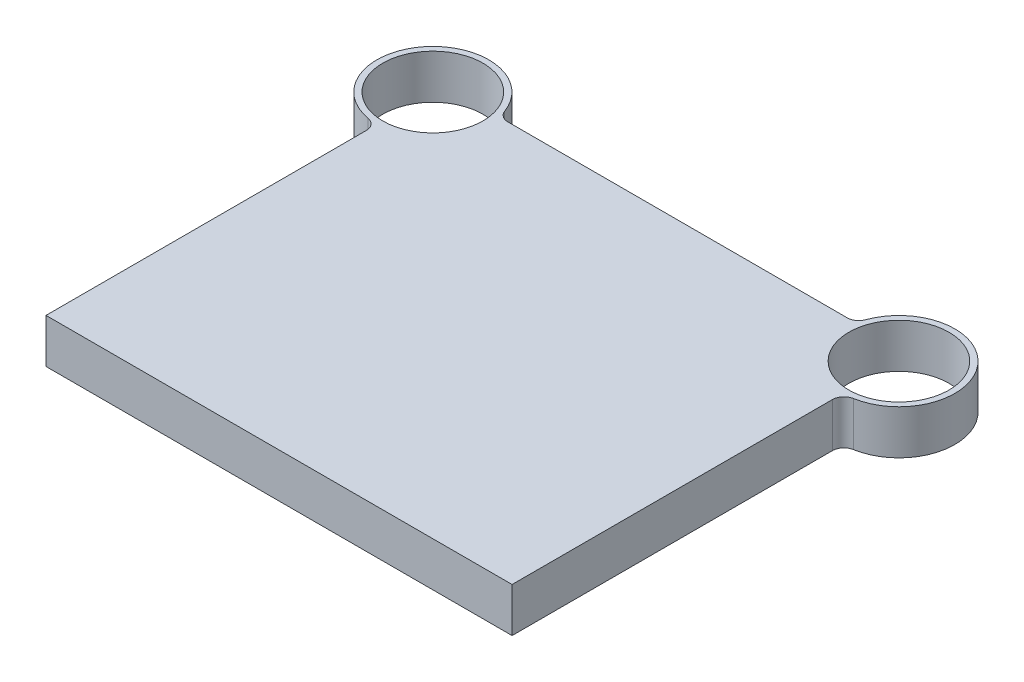
from build123d import *

# Parameters (mm, degrees)
SKETCH1_R           = 43
BOSS_EXTRUDE1_DEPTH = 38
FILLET1_R           = 10


with BuildPart() as part:
    # Sketch1 → Boss-Extrude1 (new body)
    with BuildSketch(Plane(origin=(0, 0, 0), x_dir=(1, 0, 0), z_dir=(0, 1, 0))):
        with BuildLine():
            Line((200, 0), (-200, 0))
            Line((-200, 0), (-200, 284))
            ThreePointArc((-200, 284), (-237.309516212, 362.199337741), (-153.053221623, 342))
            Line((-153.053221623, 342), (153.053221623, 342))
            ThreePointArc((153.053221623, 342), (237.309516212, 362.199337741), (200, 284))
            Line((200, 284), (200, 0))
        make_face()
        with Locations((-200, 332)):
            Circle(SKETCH1_R, mode=Mode.SUBTRACT)
        with Locations((200, 332)):
            Circle(SKETCH1_R, mode=Mode.SUBTRACT)
    extrude(amount=BOSS_EXTRUDE1_DEPTH)

    # Fillet1
    fillet1_edges = [part.edges().sort_by_distance(p)[0] for p in [
        (-200, 19, -284),
        (-153.053221623, 19, -342),
        (153.053221623, 19, -342),
        (200, 19, -284),
    ]]
    fillet(fillet1_edges, radius=FILLET1_R)


solid = part.part
